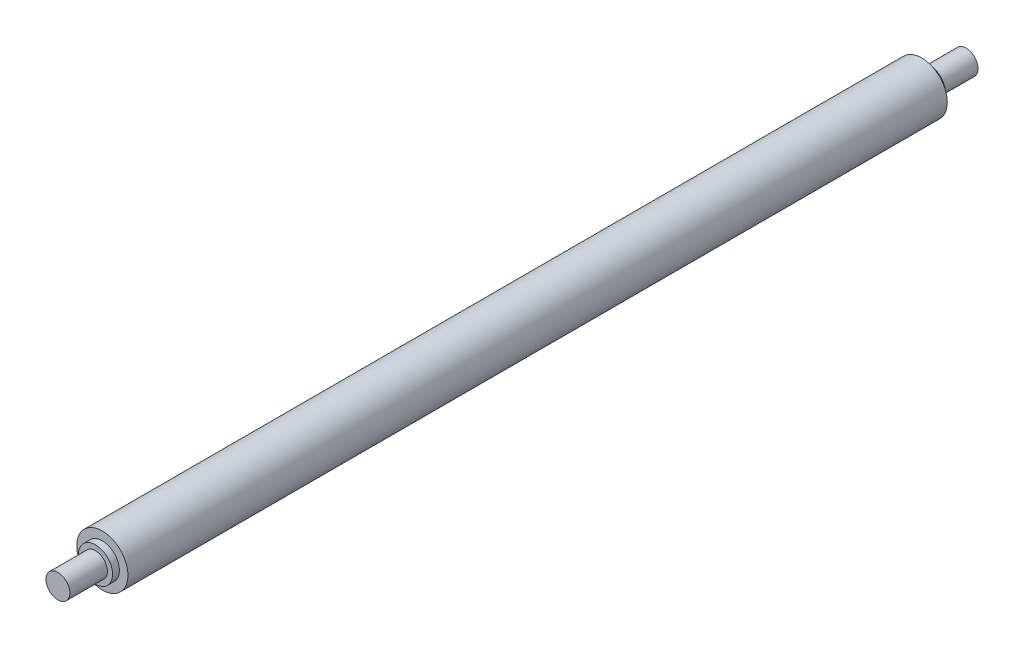
from build123d import *

# Parameters (mm, degrees)
SKETCH_1_R      = 7.5
EXTRUDE_1_DEPTH = 240
SKETCH_2_R      = 3.5
EXTRUDE_2_DEPTH = 13
SKETCH_3_R      = 3.5
EXTRUDE_3_DEPTH = 13
SKETCH_4_R      = 5
EXTRUDE_4_DEPTH = 2
SKETCH_5_R      = 5
EXTRUDE_5_DEPTH = 2


with BuildPart() as part:
    # 草图1 → 凸台-拉伸1 (new body)
    with BuildSketch(Plane.XY):
        Circle(SKETCH_1_R)
    extrude(amount=EXTRUDE_1_DEPTH)

    # 草图2 → 凸台-拉伸2 (add)
    with BuildSketch(Plane(origin=(0, 0, 0), x_dir=(-1, 0, 0), z_dir=(0, 0, -1))):
        Circle(SKETCH_2_R)
    extrude(amount=EXTRUDE_2_DEPTH)

    # 草图3 → 凸台-拉伸3 (add)
    with BuildSketch(Plane.XY.offset(240)):
        Circle(SKETCH_3_R)
    extrude(amount=EXTRUDE_3_DEPTH)

    # 草图4 → 凸台-拉伸4 (add)
    with BuildSketch(Plane(origin=(0, 0, 0), x_dir=(-1, 0, 0), z_dir=(0, 0, -1))):
        Circle(SKETCH_4_R)
    extrude(amount=EXTRUDE_4_DEPTH)

    # 草图5 → 凸台-拉伸5 (add)
    with BuildSketch(Plane.XY.offset(240)):
        Circle(SKETCH_5_R)
    extrude(amount=EXTRUDE_5_DEPTH)


solid = part.part
